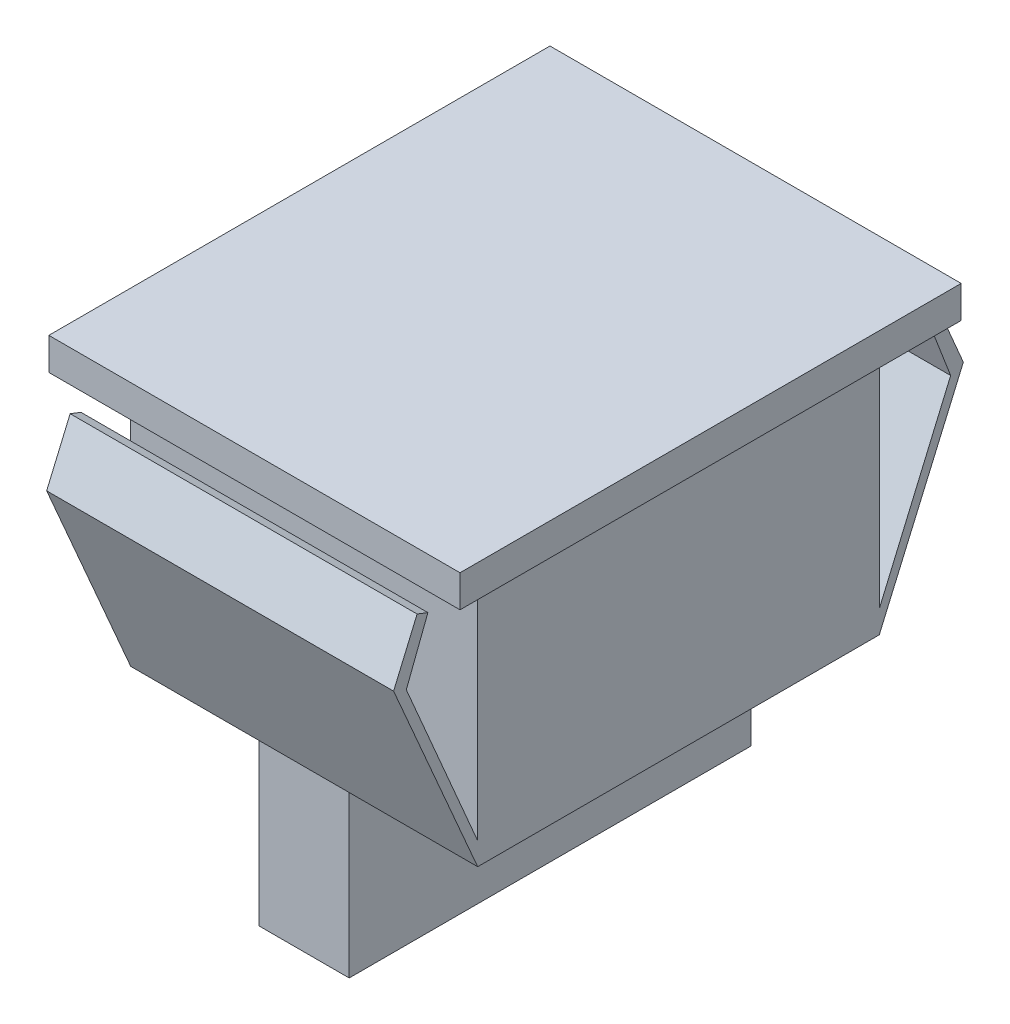
from build123d import *

# Parameters (mm, degrees)
EXTRUDE_1_DEPTH          = 25.6
SKETCH_2_OUTSIDE_W       = 38.032
SKETCH_2_OUTSIDE_H       = 40.832
CUT_EXTRUDE_1_DEPTH      = 6.235907328
CUT_EXTRUDE_1_DEPTH_BACK = 31.235907328


with BuildPart() as part:
    # Эскиз1 → Бобышка-Вытянуть1 (new body)
    with BuildSketch(Plane(origin=(0, 0, 0), x_dir=(0, 0, -1), z_dir=(1, 0, 0))):
        Polygon((12.5, 0), (-12.5, 0), (-12.5, 10), (-17.735907328, 22.085646779), (-16.27222348, 25.510475942), (-15.6, 25.25148825), (-16.94444696, 21.761867538), (-12.5, 11.400931817), (-12.5, 24.709221845), (-13.75, 24.709221845), (-13.75, 26.4), (-15.6, 26.4), (-15.6, 28.4), (15.6, 28.4), (15.6, 26.4), (13.75, 26.4), (13.75, 24.709221845), (12.5, 24.709221845), (12.5, 11.400931817), (16.94444696, 21.761867538), (15.6, 25.25148825), (16.27222348, 25.510475942), (17.735907328, 22.085646779), (12.5, 10), align=None)
    extrude(amount=EXTRUDE_1_DEPTH)

    # Эскиз2 outside → Вырез-Вытянуть1 (cut, two sides)
    with BuildSketch(Plane.XY.offset(12.5)) as cut_extrude_1_sk:
        with Locations((12.8, 14.2)):
            Rectangle(SKETCH_2_OUTSIDE_W, SKETCH_2_OUTSIDE_H)
        Polygon((2, 10), (2, 26.4), (0, 26.4), (0, 28.4), (25.6, 28.4), (25.6, 26.4), (23.6, 26.4), (23.6, 10), (15.6, 10), (15.6, 0), (10, 0), (10, 10), align=None, mode=Mode.SUBTRACT)
    extrude(amount=CUT_EXTRUDE_1_DEPTH, mode=Mode.SUBTRACT)
    extrude(cut_extrude_1_sk.sketch, amount=-CUT_EXTRUDE_1_DEPTH_BACK, mode=Mode.SUBTRACT)


solid = part.part
